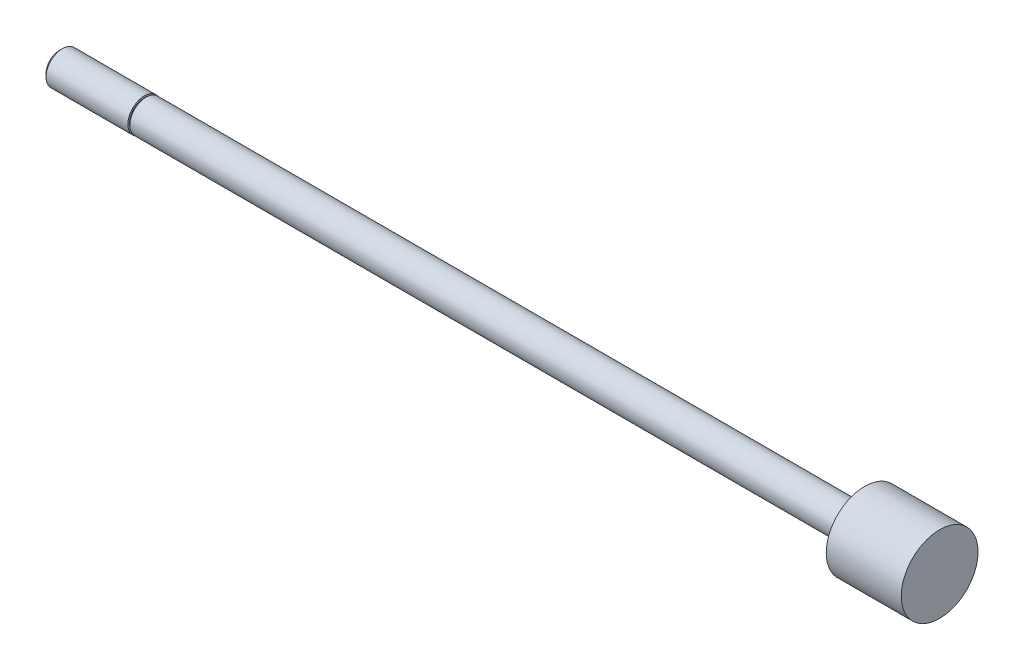
from build123d import *

# Parameters (mm, degrees)
SKETCH3_W = 0.254
SKETCH3_H = 0.508


with BuildPart() as part:
    # Sketch1 → Revolve1 (revolve)
    with BuildSketch(Plane.XY):
        Polygon((0, 0), (0, 2.3749), (105.1052, 2.3749), (105.1052, 5.61975), (116.078, 5.61975), (116.078, 0), align=None)
    revolve(axis=Axis((116.078, 0, 0), (-1, 0, 0)))

    # Sketch2 → Revolve2 (revolve)
    with BuildSketch(Plane.XY):
        Polygon((-12.7, 0), (-12.7, 1.94056), (-12.22756, 2.413), (0, 2.413), (0, 0), align=None)
    revolve(axis=Axis((0, 0, 0), (-1, 0, 0)))

    # Sketch3 → Cut-Revolve1 (revolve, cut)
    with BuildSketch(Plane.XY):
        with Locations((-0.127, 2.413)):
            Rectangle(SKETCH3_W, SKETCH3_H)
    revolve(axis=Axis((0, 0, 0), (-1, 0, 0)), mode=Mode.SUBTRACT)


solid = part.part
